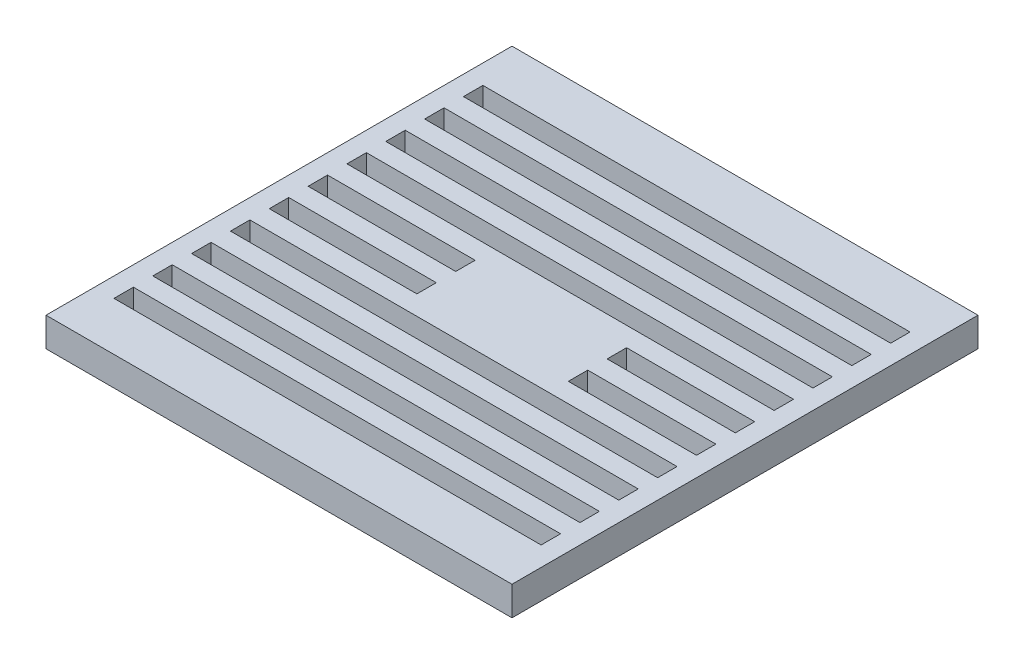
from build123d import *

# Parameters (mm, degrees)
SKETCH1_W           = 152.4
SKETCH1_H           = 152.4
BOSS_EXTRUDE1_DEPTH = 9.525
SKETCH2_W           = 139.7
SKETCH2_H           = 6.35
CUT_EXTRUDE1_DEPTH  = 10.525
LPATTERN1_COUNT     = 10
LPATTERN1_PITCH     = 12.7
SKETCH3_W           = 48.26
SKETCH3_H           = 6.35
SKETCH3_W_2         = 41.91
CUT_EXTRUDE2_DEPTH  = 9.525
LPATTERN2_COUNT     = 2
LPATTERN2_PITCH     = 12.7


with BuildPart() as part:
    # Sketch1 → Boss-Extrude1 (new body)
    with BuildSketch(Plane(origin=(0, 0, 0), x_dir=(1, 0, 0), z_dir=(0, 1, 0))):
        Rectangle(SKETCH1_W, SKETCH1_H)
    extrude(amount=BOSS_EXTRUDE1_DEPTH)

    # Sketch2 → Cut-Extrude1 (cut, through all)
    with BuildSketch(Plane.XZ):
        with Locations((0, 57.15)):
            Rectangle(SKETCH2_W, SKETCH2_H)
    cut_extrude1 = extrude(amount=-CUT_EXTRUDE1_DEPTH, mode=Mode.SUBTRACT)

    # LPattern1: Cut-Extrude1 ×10, 2 skipped
    with Locations(*[(0, 0, -i * LPATTERN1_PITCH) for i in range(1, LPATTERN1_COUNT) if i not in (4, 5)]):
        add(cut_extrude1, mode=Mode.SUBTRACT)

    # Sketch3 → Cut-Extrude2 (cut)
    with BuildSketch(Plane.XZ):
        with Locations((-45.72, 6.35)):
            Rectangle(SKETCH3_W, SKETCH3_H)
        with Locations((48.895, 6.35)):
            Rectangle(SKETCH3_W_2, SKETCH3_H)
    cut_extrude2 = extrude(amount=-CUT_EXTRUDE2_DEPTH, mode=Mode.SUBTRACT)

    # LPattern2: Cut-Extrude2 ×2
    with Locations(*[(0, 0, -i * LPATTERN2_PITCH) for i in range(1, LPATTERN2_COUNT)]):
        add(cut_extrude2, mode=Mode.SUBTRACT)


solid = part.part
